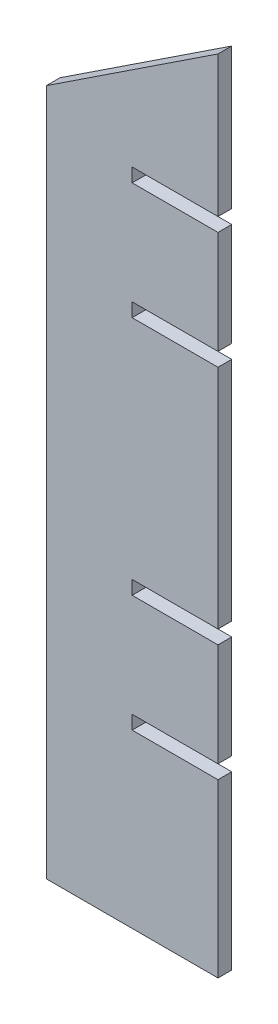
from build123d import *

# Parameters (mm, degrees)
BOSS_EXTRU_1_DEPTH = 4


with BuildPart() as part:
    # Esquisse1 → Boss.-Extru.1 (new body)
    with BuildSketch(Plane.XY):
        Polygon((-114.064870184, 137.682235243), (-114.064870184, -62.317764757), (-64.064870184, -62.317764757), (-64.064870184, -12.317764757), (-89.064870184, -12.317764757), (-89.064870184, -8.317764757), (-64.064870184, -8.317764757), (-64.064870184, 21.682235243), (-89.064870184, 21.682235243), (-89.064870184, 25.682235243), (-64.064870184, 25.682235243), (-64.064870184, 91.682235243), (-89.064870184, 91.682235243), (-89.064870184, 95.682235243), (-64.064870184, 95.682235243), (-64.064870184, 125.682235243), (-89.064870184, 125.682235243), (-89.064870184, 129.682235243), (-64.064870184, 129.682235243), (-64.064870184, 170.682235243), align=None)
    extrude(amount=BOSS_EXTRU_1_DEPTH)


solid = part.part
